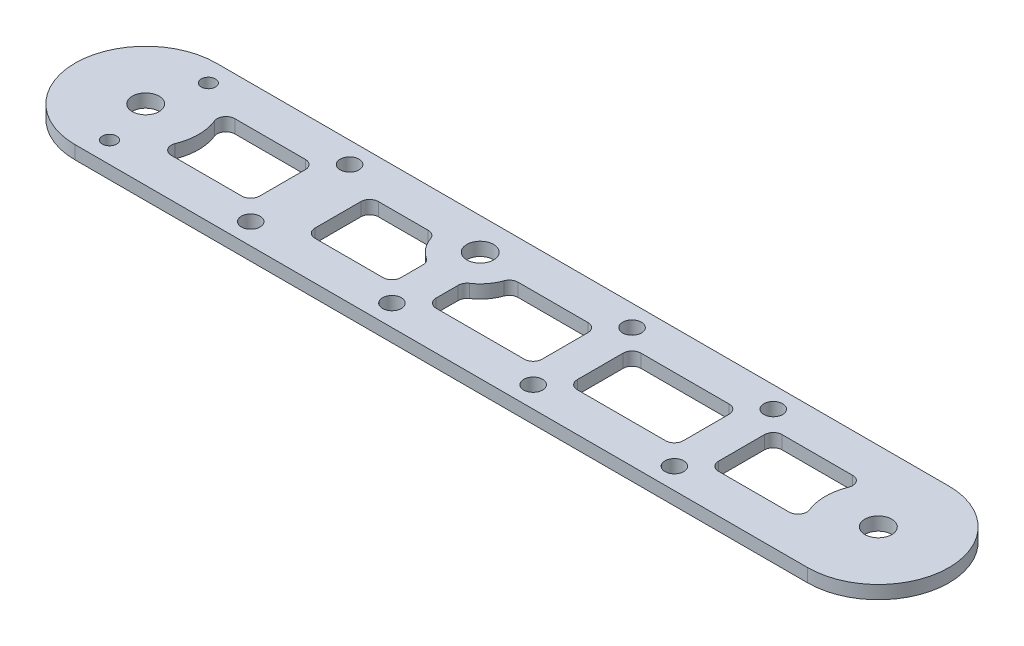
from build123d import *

# Parameters (mm, degrees)
SKETCH1_R           = 4.826
SKETCH1_R_2         = 3.3782
SKETCH1_R_3         = 2.5527
BOSS_EXTRUDE1_DEPTH = 4.7625


with BuildPart() as part:
    # Sketch1 → Boss-Extrude1 (new body)
    with BuildSketch(Plane(origin=(0, 4.7625, 0), x_dir=(1, 0, 0), z_dir=(0, 1, 0))):
        with BuildLine():
            Line((263.525, 25.4), (0, 25.4))
            ThreePointArc((0, 25.4), (-25.4, 0), (0, -25.4))
            Line((0, -25.4), (263.525, -25.4))
            ThreePointArc((263.525, -25.4), (288.925, 0), (263.525, 25.4))
        make_face()
        Circle(SKETCH1_R, mode=Mode.SUBTRACT)
        with Locations((263.525, 0)):
            Circle(SKETCH1_R, mode=Mode.SUBTRACT)
        with Locations((55.5625, -17.78)):
            Circle(SKETCH1_R_2, mode=Mode.SUBTRACT)
        with Locations((4.7625, -17.78)):
            Circle(SKETCH1_R_3, mode=Mode.SUBTRACT)
        with Locations((207.9625, 17.78)):
            Circle(SKETCH1_R_2, mode=Mode.SUBTRACT)
        with Locations((106.3625, -17.78)):
            Circle(SKETCH1_R_2, mode=Mode.SUBTRACT)
        with Locations((157.1625, -17.78)):
            Circle(SKETCH1_R_2, mode=Mode.SUBTRACT)
        with Locations((207.9625, -17.78)):
            Circle(SKETCH1_R_2, mode=Mode.SUBTRACT)
        with Locations((157.1625, 17.78)):
            Circle(SKETCH1_R_2, mode=Mode.SUBTRACT)
        with Locations((4.7625, 17.78)):
            Circle(SKETCH1_R_3, mode=Mode.SUBTRACT)
        with Locations((55.5625, 17.78)):
            Circle(SKETCH1_R_2, mode=Mode.SUBTRACT)
        with Locations((106.3625, 13.97)):
            Circle(SKETCH1_R, mode=Mode.SUBTRACT)
        with BuildLine():
            Line((166.6875, 11.43), (198.4375, 11.43))
            ThreePointArc((198.4375, 11.43), (200.68256403, 10.50006403), (201.6125, 8.255))
            Line((201.6125, 8.255), (201.6125, -8.255))
            ThreePointArc((201.6125, -8.255), (200.68256403, -10.50006403), (198.4375, -11.43))
            Line((198.4375, -11.43), (166.6875, -11.43))
            ThreePointArc((166.6875, -11.43), (164.44243597, -10.50006403), (163.5125, -8.255))
            Line((163.5125, -8.255), (163.5125, 8.255))
            ThreePointArc((163.5125, 8.255), (164.44243597, 10.50006403), (166.6875, 11.43))
        make_face(mode=Mode.SUBTRACT)
        with BuildLine():
            Line((122.526961018, 11.43), (147.6375, 11.43))
            ThreePointArc((147.6375, 11.43), (149.88256403, 10.50006403), (150.8125, 8.255))
            Line((150.8125, 8.255), (150.8125, -8.255))
            ThreePointArc((150.8125, -8.255), (149.88256403, -10.50006403), (147.6375, -11.43))
            Line((147.6375, -11.43), (115.8875, -11.43))
            ThreePointArc((115.8875, -11.43), (113.64243597, -10.50006403), (112.7125, -8.255))
            Line((112.7125, -8.255), (112.7125, -0.285714644))
            ThreePointArc((112.7125, -0.285714644), (113.087413196, 1.21099471), (114.123611111, 2.354232513))
            ThreePointArc((114.123611111, 2.354232513), (117.391826035, 5.39591887), (119.533542311, 9.313333333))
            ThreePointArc((119.533542311, 9.313333333), (120.693873913, 10.847376644), (122.526961018, 11.43))
        make_face(mode=Mode.SUBTRACT)
        with BuildLine():
            Line((72.306560788, 11.43), (90.198038982, 11.43))
            ThreePointArc((90.198038982, 11.43), (92.031126087, 10.847376644), (93.191457689, 9.313333333))
            ThreePointArc((93.191457689, 9.313333333), (95.333173965, 5.39591887), (98.601388889, 2.354232513))
            ThreePointArc((98.601388889, 2.354232513), (99.637586804, 1.21099471), (100.0125, -0.285714644))
            Line((100.0125, -0.285714644), (100.0125, -8.255))
            ThreePointArc((100.0125, -8.255), (99.08256403, -10.50006403), (96.8375, -11.43))
            Line((96.8375, -11.43), (72.306560788, -11.43))
            ThreePointArc((72.306560788, -11.43), (70.061496758, -10.50006403), (69.131560788, -8.255))
            Line((69.131560788, -8.255), (69.131560788, 8.255))
            ThreePointArc((69.131560788, 8.255), (70.061496758, 10.50006403), (72.306560788, 11.43))
        make_face(mode=Mode.SUBTRACT)
        with BuildLine():
            Line((20.635057548, 11.43), (46.0375, 11.43))
            ThreePointArc((46.0375, 11.43), (48.28256403, 10.50006403), (49.2125, 8.255))
            Line((49.2125, 8.255), (49.2125, -8.255))
            ThreePointArc((49.2125, -8.255), (48.28256403, -10.50006403), (46.0375, -11.43))
            Line((46.0375, -11.43), (20.635057548, -11.43))
            ThreePointArc((20.635057548, -11.43), (18.005907767, -10.034942816), (17.687192184, -7.075714286))
            ThreePointArc((17.687192184, -7.075714286), (19.05, 0), (17.687192184, 7.075714286))
            ThreePointArc((17.687192184, 7.075714286), (18.005907767, 10.034942816), (20.635057548, 11.43))
        make_face(mode=Mode.SUBTRACT)
        with BuildLine():
            Line((242.889942452, -11.43), (217.4875, -11.43))
            ThreePointArc((217.4875, -11.43), (215.24243597, -10.50006403), (214.3125, -8.255))
            Line((214.3125, -8.255), (214.3125, 8.255))
            ThreePointArc((214.3125, 8.255), (215.24243597, 10.50006403), (217.4875, 11.43))
            Line((217.4875, 11.43), (242.889942452, 11.43))
            ThreePointArc((242.889942452, 11.43), (245.519092233, 10.034942816), (245.837807816, 7.075714286))
            ThreePointArc((245.837807816, 7.075714286), (244.475, 0), (245.837807816, -7.075714286))
            ThreePointArc((245.837807816, -7.075714286), (245.519092233, -10.034942816), (242.889942452, -11.43))
        make_face(mode=Mode.SUBTRACT)
    extrude(amount=-BOSS_EXTRUDE1_DEPTH)


solid = part.part
